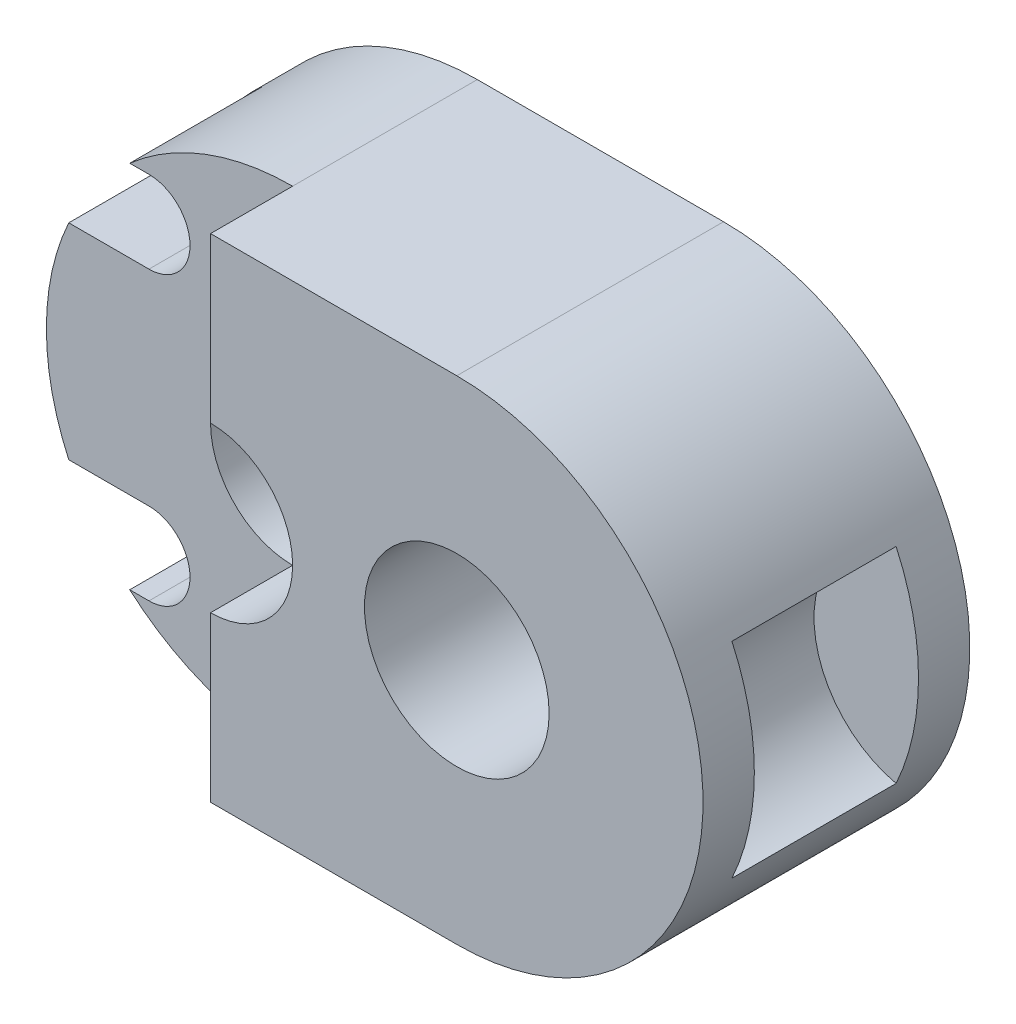
from build123d import *

# Parameters (mm, degrees)
SKETCH1_R                              = 0.5
BOSS_EXTRUDE1_DEPTH                    = 3.25
CUT_EXTRUDE1_DEPTH                     = 2
SKETCH3_W                              = 9.709711208
SKETCH3_H                              = 13.055758796
CUT_EXTRUDE2_DEPTH                     = 2
CUT_EXTRUDE3_DEPTH                     = 3.5
SKETCH5_R                              = 2.25
CUT_EXTRUDE4_DEPTH                     = 3.5
CUT_EXTRUDE5_DEPTH                     = 3.25
M1_2X0_25_TAPPED_HOLE1_D               = 0.95
M1_2X0_25_TAPPED_HOLE1_DEPTH           = 13.65
M1_2X0_25_TAPPED_HOLE1_TIP             = 0.285408794
M1_2X0_25_TAPPED_HOLE1_ON_FACE_2_D     = 0.95
M1_2X0_25_TAPPED_HOLE1_ON_FACE_2_DEPTH = 13.65
M1_2X0_25_TAPPED_HOLE1_ON_FACE_2_TIP   = 0.285408794


with BuildPart() as part:
    # Sketch1 → Boss-Extrude1 (new, symmetric)
    with BuildSketch(Plane.XY):
        with BuildLine():
            Line((-3, 6), (3, 6))
            ThreePointArc((3, 6), (9, 0), (3, -6))
            Line((3, -6), (-3, -6))
            ThreePointArc((-3, -6), (-9, 0), (-3, 6))
        make_face()
        with Locations((-3, 0)):
            Circle(SKETCH1_R, mode=Mode.SUBTRACT)
    extrude(amount=BOSS_EXTRUDE1_DEPTH, both=True)

    # Sketch2 → Cut-Extrude1 (cut, symmetric)
    with BuildSketch(Plane.XY):
        with BuildLine():
            ThreePointArc((8.454356057, 2.5), (6.454356057, 0), (8.454356057, -2.5))
            ThreePointArc((8.454356057, -2.5), (9, 0), (8.454356057, 2.5))
        make_face()
    extrude(amount=CUT_EXTRUDE1_DEPTH, both=True, mode=Mode.SUBTRACT)

    # Sketch3 → Cut-Extrude2 (cut)
    with BuildSketch(Plane.XY.offset(3.25)):
        with Locations((-7.854855604, -0.527879398)):
            Rectangle(SKETCH3_W, SKETCH3_H)
    extrude(amount=-CUT_EXTRUDE2_DEPTH, mode=Mode.SUBTRACT)

    # Sketch4 → Cut-Extrude3 (cut)
    with BuildSketch(Plane.XY.offset(3.25)):
        with BuildLine():
            ThreePointArc((-3, 2), (-5, 0), (-3, -2))
            ThreePointArc((-3, -2), (-1, 0), (-3, 2))
        make_face()
    extrude(amount=-CUT_EXTRUDE3_DEPTH, mode=Mode.SUBTRACT)

    # Sketch5 → Cut-Extrude4 (cut)
    with BuildSketch(Plane.XY.offset(3.25)):
        with Locations((3, 0)):
            Circle(SKETCH5_R)
    extrude(amount=-CUT_EXTRUDE4_DEPTH, mode=Mode.SUBTRACT)

    # Sketch6 → Cut-Extrude5 (cut)
    with BuildSketch(Plane.XY.offset(1.25)):
        with BuildLine():
            ThreePointArc((-6.5, -4.5), (-5.5, -3.5), (-6.5, -2.5))
            Line((-6.5, -2.5), (-8.454356057, -2.5))
            ThreePointArc((-8.454356057, -2.5), (-7.81644602, -3.577966983), (-6.968626967, -4.5))
            Line((-6.968626967, -4.5), (-6.5, -4.5))
        make_face()
        with BuildLine():
            ThreePointArc((-6.5, 2.5), (-5.5, 3.5), (-6.5, 4.5))
            Line((-6.5, 4.5), (-6.968626967, 4.5))
            ThreePointArc((-6.968626967, 4.5), (-7.81644602, 3.577966983), (-8.454356057, 2.5))
            Line((-8.454356057, 2.5), (-6.5, 2.5))
        make_face()
    extrude(amount=-CUT_EXTRUDE5_DEPTH, mode=Mode.SUBTRACT)

    # M1.2x0.25 Tapped Hole1
    with Locations(Plane(origin=(3, 0, -0.25), x_dir=(1, 0, 0), z_dir=(0, 0, 1))):
        with Locations((0, 0)):
            Hole(M1_2X0_25_TAPPED_HOLE1_D / 2, depth=M1_2X0_25_TAPPED_HOLE1_DEPTH)
            with Locations((0, 0, -(M1_2X0_25_TAPPED_HOLE1_DEPTH + M1_2X0_25_TAPPED_HOLE1_TIP / 2))):  # 118° drill point
                Cone(0, M1_2X0_25_TAPPED_HOLE1_D / 2, M1_2X0_25_TAPPED_HOLE1_TIP, mode=Mode.SUBTRACT)

    # M1.2x0.25 Tapped Hole1 on face 2
    with Locations(Plane(origin=(-6.5, 3.5, -2), x_dir=(1, 0, 0), z_dir=(0, 0, 1))):
        with Locations((0, 0), (0, -7)):
            Hole(M1_2X0_25_TAPPED_HOLE1_ON_FACE_2_D / 2, depth=M1_2X0_25_TAPPED_HOLE1_ON_FACE_2_DEPTH)
            with Locations((0, 0, -(M1_2X0_25_TAPPED_HOLE1_ON_FACE_2_DEPTH + M1_2X0_25_TAPPED_HOLE1_ON_FACE_2_TIP / 2))):  # 118° drill point
                Cone(0, M1_2X0_25_TAPPED_HOLE1_ON_FACE_2_D / 2, M1_2X0_25_TAPPED_HOLE1_ON_FACE_2_TIP, mode=Mode.SUBTRACT)


solid = part.part
